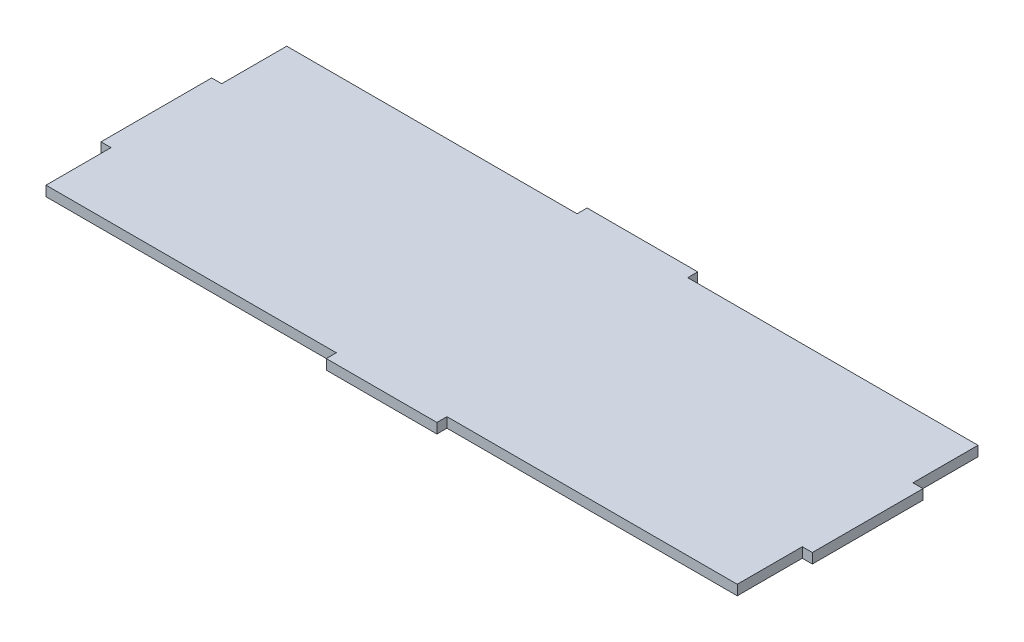
from build123d import *

# Parameters (mm, degrees)
BOSS_EXTRUDE1_DEPTH = 6.35


with BuildPart() as part:
    # Sketch1 → Boss-Extrude1 (new body)
    with BuildSketch(Plane(origin=(0, 0, 0), x_dir=(1, 0, 0), z_dir=(0, 1, 0))):
        Polygon((35, -82.5), (-35, -82.5), (-35, -76.15), (-218.65, -76.15), (-218.65, -35), (-225, -35), (-225, 35), (-218.65, 35), (-218.65, 76.15), (-35, 76.15), (-35, 82.5), (35, 82.5), (35, 76.15), (218.65, 76.15), (218.65, 35), (225, 35), (225, -35), (218.65, -35), (218.65, -76.15), (35, -76.15), align=None)
    extrude(amount=BOSS_EXTRUDE1_DEPTH)


solid = part.part
